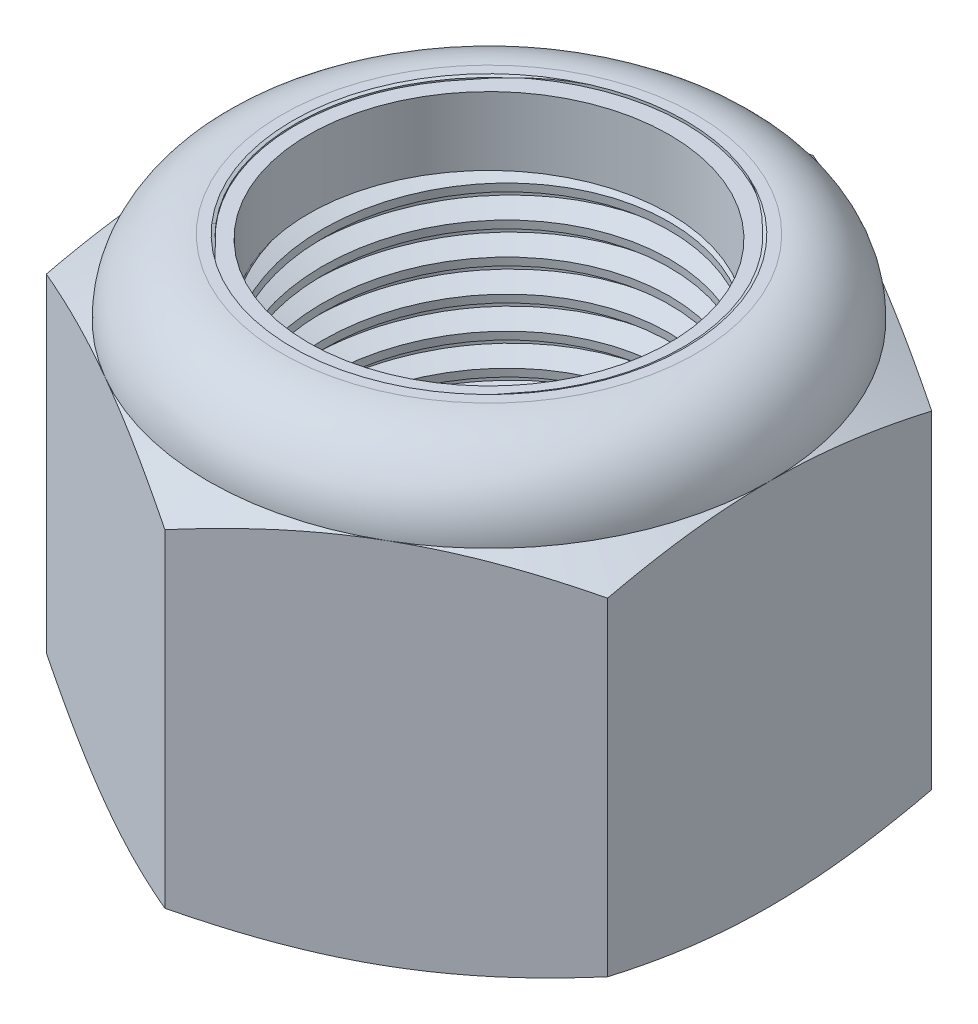
from build123d import *

# Parameters (mm, degrees)
EXTRUDE1_DEPTH      = 25.003125
SKETCH2_W           = 11.1125
SKETCH2_H           = 25.003125
LPATTERN1_COUNT     = 14
LPATTERN1_PITCH     = 1.814285714
LPATTERN1_COL_COUNT = 2
LPATTERN1_COL_PITCH = 1.814285714


with BuildPart() as part:
    # Sketch1 → Extrude1 (new body)
    with BuildSketch(Plane(origin=(0, 0, 0), x_dir=(1, 0, 0), z_dir=(0, 1, 0))):
        Polygon((0, 18.330871047), (-15.875, 9.165435523), (-15.875, -9.165435523), (0, -18.330871047), (15.875, -9.165435523), (15.875, 9.165435523), align=None)
    extrude(amount=EXTRUDE1_DEPTH)

    # Sketch4 → Cut-Revolve2 (revolve, cut)
    with BuildSketch(Plane(origin=(0, 0, 0), x_dir=(0, 0, -1), z_dir=(1, 0, 0))):
        Polygon((0, 25.003125), (11.1125, 25.003125), (10.19832589, 24.576838611), (10.19832589, 0.426286389), (11.1125, 0), (0, 0), align=None)
    revolve(axis=Axis((0, 25.003125, 0), (0, 1, 0)), mode=Mode.SUBTRACT)


with BuildPart() as body_2:
    # Sketch2 → Revolve1 (revolve)
    with BuildSketch(Plane(origin=(0, 0, 0), x_dir=(0, 0, -1), z_dir=(1, 0, 0))):
        with Locations((5.55625, 12.5015625)):
            Rectangle(SKETCH2_W, SKETCH2_H)
    revolve(axis=Axis((0, -11.1125, 0), (0, 1, 0)))

    # Sketch3 → Cut-Revolve1 (revolve, cut)
    with BuildSketch(Plane(origin=(0, 0, 0), x_dir=(0, 0, -1), z_dir=(1, 0, 0))):
        Polygon((11.130951741, 24.777091167), (11.260113931, 23.19485434), (10.235229372, 23.680040537), (10.19832589, 24.132108202), align=None)
    cut_revolve1 = revolve(axis=Axis((0, 25.003125, 0.157638636), (0, -0.996684616, -0.081362009)), mode=Mode.SUBTRACT)

    # LPattern1: Cut-Revolve1 ×14
    with Locations(*[(0, -i * LPATTERN1_PITCH, 0) for i in range(1, LPATTERN1_COUNT)]):
        add(cut_revolve1, mode=Mode.SUBTRACT)

    # LPattern1 col: Cut-Revolve1 ×2
    with Locations(*[(0, i * LPATTERN1_COL_PITCH, 0) for i in range(1, LPATTERN1_COL_COUNT)]):
        add(cut_revolve1, mode=Mode.SUBTRACT)


with BuildPart() as part_1:
    add(part.part)

    # Combine1: cut body 2
    add(body_2.part, mode=Mode.SUBTRACT)

    # Sketch5 → Cut-Revolve3 (revolve, cut)
    with BuildSketch(Plane(origin=(0, 0, 0), x_dir=(0, 0, -1), z_dir=(1, 0, 0))):
        with BuildLine():
            Line((0, 0), (15.875, 0))
            Line((15.875, 0), (18.330871047, 1.145191477))
            Line((18.330871047, 1.145191477), (18.330871047, 19.690746023))
            Line((18.330871047, 19.690746023), (15.875, 20.8359375))
            ThreePointArc((15.875, 20.8359375), (14.65445904, 23.78258404), (11.7078125, 25.003125))
            Line((11.7078125, 25.003125), (11.7078125, 26.273125))
            Line((11.7078125, 26.273125), (19.600871047, 26.273125))
            Line((19.600871047, 26.273125), (19.600871047, -1.27))
            Line((19.600871047, -1.27), (0, -1.27))
            Line((0, -1.27), (0, 0))
        make_face()
    revolve(axis=Axis((0, 0, 0), (0, 1, 0)), mode=Mode.SUBTRACT)

    # Sketch6 → Cut-Revolve4 (revolve, cut)
    with BuildSketch(Plane(origin=(0, 0, 0), x_dir=(0, 0, -1), z_dir=(1, 0, 0))):
        with BuildLine():
            Line((0, 20.8359375), (15.7226, 20.8359375))
            ThreePointArc((15.7226, 20.8359375), (14.546695966, 23.674820966), (11.7078125, 24.850725))
            Line((11.7078125, 24.850725), (10.953069195, 24.850725))
            Line((10.953069195, 24.850725), (10.953069195, 26.273125))
            Line((10.953069195, 26.273125), (0, 26.273125))
            Line((0, 26.273125), (0, 20.8359375))
        make_face()
    revolve(axis=Axis((0, 26.273125, 0), (0, 1, 0)), mode=Mode.SUBTRACT)


with BuildPart() as body_2_2:
    # Sketch7 → Revolve2 (revolve)
    with BuildSketch(Plane(origin=(0, 0, 0), x_dir=(0, 0, -1), z_dir=(1, 0, 0))):
        with BuildLine():
            Line((10.19832589, 20.9121375), (15.645662809, 20.9121375))
            ThreePointArc((15.645662809, 20.9121375), (14.465742079, 23.647751137), (11.7078125, 24.774525))
            Line((11.7078125, 24.774525), (10.19832589, 24.774525))
            Line((10.19832589, 24.774525), (10.19832589, 20.9121375))
        make_face()
    revolve(axis=Axis((0, 20.9121375, 0), (0, 1, 0)))


solid = Compound([part_1.part, body_2_2.part])
